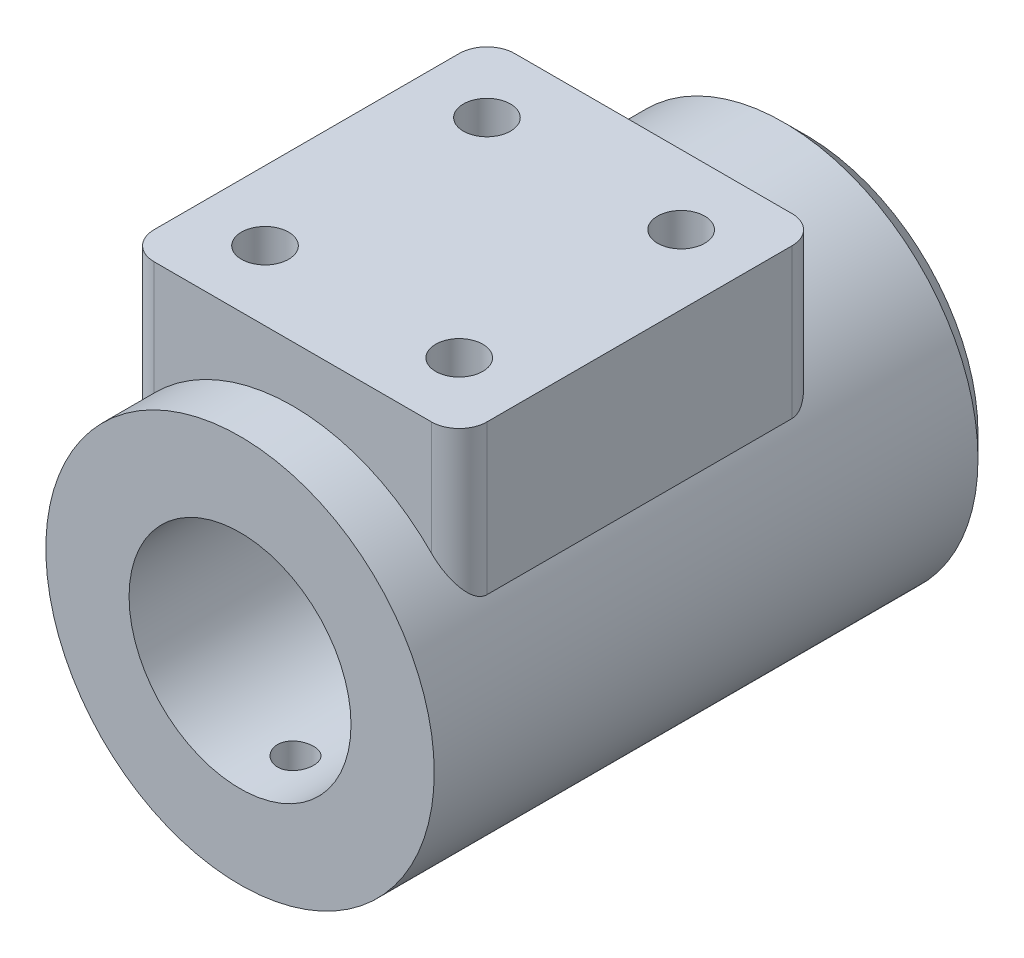
from build123d import *

# Parameters (mm, degrees)
ESBO_O1_R                = 35
RESSALTO_EXTRUS_O1_DEPTH = 51
RESSALTO_EXTRUS_O2_DEPTH = 45
CHANFRO1_SIZE            = 4
ESBO_O4_R                = 4.25
CORTE_EXTRUS_O1_DEPTH    = 20
ESBO_O5_R                = 3.25
CORTE_EXTRUS_O2_DEPTH    = 36.0000001


with BuildPart() as part:
    # Esboço1 → Ressalto-extrusão1 (new body, symmetric)
    with BuildSketch(Plane.XY):
        Circle(ESBO_O1_R)
    extrude(amount=RESSALTO_EXTRUS_O1_DEPTH, both=True)

    # Esboço3 → Ressalto-extrusão2 (add)
    with BuildSketch(Plane(origin=(0, 0, 0), x_dir=(1, 0, 0), z_dir=(0, 1, 0))):
        with BuildLine():
            Line((-25, -41.5), (25, -41.5))
            ThreePointArc((25, -41.5), (28.535533906, -40.035533906), (30, -36.5))
            Line((30, -36.5), (30, 18.5))
            ThreePointArc((30, 18.5), (28.535533906, 22.035533906), (25, 23.5))
            Line((25, 23.5), (-25, 23.5))
            ThreePointArc((-25, 23.5), (-28.535533906, 22.035533906), (-30, 18.5))
            Line((-30, 18.5), (-30, -36.5))
            ThreePointArc((-30, -36.5), (-28.535533906, -40.035533906), (-25, -41.5))
        make_face()
    extrude(amount=RESSALTO_EXTRUS_O2_DEPTH)

    # Esboço2 → Corte-Revolução1 (revolve, cut)
    with BuildSketch(Plane(origin=(0, 0, 0), x_dir=(0, 0, -1), z_dir=(1, 0, 0)), mode=Mode.PRIVATE) as corte_revolu_o1_sk:
        Polygon((51, 25), (42.2, 25), (42.2, 26.5), (41, 26.5), (41, 25), (16, 25), (16, 20), (-51, 20), (-51, 0), (51, 0), align=None)
    revolve(corte_revolu_o1_sk.sketch.rotate(Axis((0, 0, 52.957916626), (0, 0, -1)), 90), axis=Axis((0, 0, 52.957916626), (0, 0, -1)), mode=Mode.SUBTRACT)  # turned: the seam where the file's is

    # Chanfro1
    chanfro1_edges = [part.edges().sort_by_distance(p)[0] for p in [
        (-35, 0, -51),
    ]]
    chamfer(chanfro1_edges, length=CHANFRO1_SIZE)

    # Esboço4 → Corte-extrusão1 (cut)
    with BuildSketch(Plane(origin=(0, 45, 0), x_dir=(1, 0, 0), z_dir=(0, 1, 0))):
        with Locations(Location((-17.5, 11, 0), (0, 0, 270))):  # turned: the seam where the file's is
            Circle(ESBO_O4_R)
        with Locations(Location((17.5, 11, 0), (0, 0, 90))):  # turned: the seam where the file's is
            Circle(ESBO_O4_R)
        with Locations(Location((17.5, -29, 0), (0, 0, 270))):  # turned: the seam where the file's is
            Circle(ESBO_O4_R)
        with Locations(Location((-17.5, -29, 0), (0, 0, 90))):  # turned: the seam where the file's is
            Circle(ESBO_O4_R)
    extrude(amount=-CORTE_EXTRUS_O1_DEPTH, mode=Mode.SUBTRACT)

    # Esboço5 → Corte-extrusão2 (cut, through all)
    with BuildSketch(Plane(origin=(0, 0, 0), x_dir=(1, 0, 0), z_dir=(0, 1, 0))):
        with Locations(Location((0, -41, 0), (0, 0, 270))):  # turned: the seam where the file's is
            Circle(ESBO_O5_R)
    extrude(amount=-CORTE_EXTRUS_O2_DEPTH, mode=Mode.SUBTRACT)


solid = part.part
